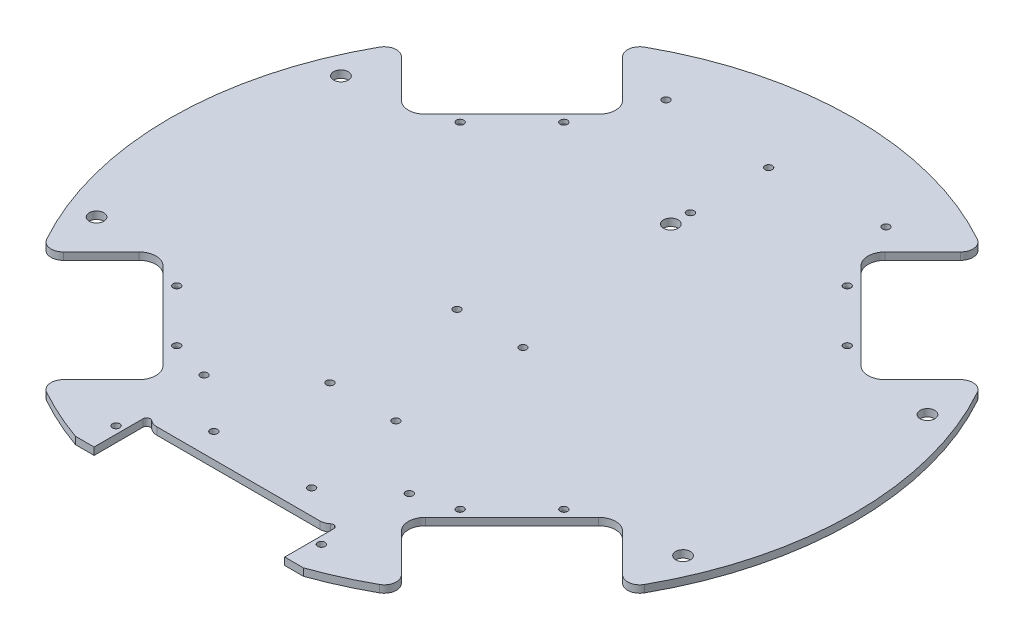
from build123d import *

# Parameters (mm, degrees)
SKETCH1_R                = 140
BOSS_EXTRUDE1_DEPTH      = 3
CUT_EXTRUDE4_DEPTH       = 3
SKETCH9_R                = 1.5
CUT_EXTRUDE6_DEPTH       = 3
FILLET1_R                = 5
CIRPATTERN1_COUNT        = 4
FILLET1_OF_CIRPATTERN1_R = 5
CUT_EXTRUDE1_REACH       = 5
FILLET3_R                = 1.5
CUT_EXTRUDE7_REACH       = 5
SKETCH10_R               = 1.5
CUT_EXTRUDE8_REACH       = 5
SKETCH11_R               = 1.5
CUT_EXTRUDE9_REACH       = 5
SKETCH13_R               = 1.5
CUT_EXTRUDE12_REACH      = 5
SKETCH16_R               = 1.5
SKETCH16_R_2             = 3
CUT_EXTRUDE13_REACH      = 5
SKETCH17_R               = 3


with BuildPart() as part:
    # Sketch1 → Boss-Extrude1 (new body)
    with BuildSketch(Plane(origin=(0, 0, 0), x_dir=(1, 0, 0), z_dir=(0, 1, 0))):
        Circle(SKETCH1_R)
    extrude(amount=BOSS_EXTRUDE1_DEPTH)

    # Sketch7 → Cut-Extrude4 (cut)
    with BuildSketch(Plane(origin=(0, 3, 0), x_dir=(1, 0, 0), z_dir=(0, 1, 0))):
        with BuildLine():
            Line((-89.130809769, -53.704760031), (-53.704760031, -89.130809769))
            ThreePointArc((-53.704760031, -89.130809769), (-51.66915216, -94.045201898), (-53.704760031, -98.959594027))
            Line((-53.704760031, -98.959594027), (-76.367532368, -121.622366364))
            Line((-76.367532368, -121.622366364), (-121.622366364, -76.367532368))
            Line((-121.622366364, -76.367532368), (-98.959594027, -53.704760031))
            ThreePointArc((-98.959594027, -53.704760031), (-94.045201898, -51.66915216), (-89.130809769, -53.704760031))
        make_face()
    cut_extrude4 = extrude(amount=-CUT_EXTRUDE4_DEPTH, mode=Mode.SUBTRACT)

    # Sketch9 → Cut-Extrude6 (cut)
    with BuildSketch(Plane(origin=(0, 3, 0), x_dir=(1, 0, 0), z_dir=(0, 1, 0))):
        with Locations((-79.195959493, -57.982756057)):
            Circle(SKETCH9_R)
        with Locations((-57.982756057, -79.195959493)):
            Circle(SKETCH9_R)
    cut_extrude6 = extrude(amount=-CUT_EXTRUDE6_DEPTH, mode=Mode.SUBTRACT)

    # Fillet1
    fillet1_edges = [part.edges().sort_by_distance(p)[0] for p in [
        (-119.001687423, 1.5, 73.746853427),
        (-73.746853427, 1.5, 119.001687423),
    ]]
    fillet(fillet1_edges, radius=FILLET1_R)

    # CirPattern1: Cut-Extrude4, Cut-Extrude6 ×4 about axis
    cirpattern1_axis = Axis((0, 0, 0), (0, 1, 0))
    for i in range(1, CIRPATTERN1_COUNT):
        add(cut_extrude4.rotate(cirpattern1_axis, i * 360 / CIRPATTERN1_COUNT), mode=Mode.SUBTRACT)
        add(cut_extrude6.rotate(cirpattern1_axis, i * 360 / CIRPATTERN1_COUNT), mode=Mode.SUBTRACT)

    # Fillet1 of CirPattern1
    fillet1_of_cirpattern1_edges = [part.edges().sort_by_distance(p)[0] for p in [
        (73.746853427, 1.5, 119.001687423),
        (119.001687423, 1.5, 73.746853427),
        (119.001687423, 1.5, -73.746853427),
        (73.746853427, 1.5, -119.001687423),
        (-73.746853427, 1.5, -119.001687423),
        (-119.001687423, 1.5, -73.746853427),
    ]]
    fillet(fillet1_of_cirpattern1_edges, radius=FILLET1_OF_CIRPATTERN1_R)

    # Sketch2 → Cut-Extrude1 (cut, up to next)
    with BuildSketch(Plane(origin=(0, 3, 0), x_dir=(1, 0, 0), z_dir=(0, 1, 0)), mode=Mode.PRIVATE) as cut_extrude1_sk1:
        with BuildLine():
            Line((-46.647615159, -132), (-39, -132))
            Line((-39, -132), (-39, -112))
            ThreePointArc((-39, -112), (-38.137304912, -110.642118396), (-36.5415434, -110.846153846))
            ThreePointArc((-36.5415434, -110.846153846), (-35.04510362, -111.702699716), (-33.346688069, -112))
            Line((-33.346688069, -112), (33.346688069, -112))
            ThreePointArc((33.346688069, -112), (35.04510362, -111.702699716), (36.5415434, -110.846153846))
            ThreePointArc((36.5415434, -110.846153846), (38.137304912, -110.642118396), (39, -112))
            Line((39, -112), (39, -132))
            Line((39, -132), (46.647615159, -132))
            Line((46.647615159, -132), (46.647615159, -140))
            Line((46.647615159, -140), (-46.647615159, -140))
            Line((-46.647615159, -140), (-46.647615159, -132))
        make_face()
    cut_extrude1_tool1 = extrude(cut_extrude1_sk1.sketch, amount=-CUT_EXTRUDE1_REACH, mode=Mode.PRIVATE) & part.part
    add(cut_extrude1_tool1.solids().sort_by_distance((0, 3, 126.474871))[0], mode=Mode.SUBTRACT)

    # Fillet3
    fillet3_edges = [part.edges().sort_by_distance(p)[0] for p in [
        (57.982756057, 0, 80.695959493),
        (79.195959493, 0, 59.482756057),
        (80.695959493, 0, -57.982756057),
        (59.482756057, 0, -79.195959493),
        (-57.982756057, 0, -80.695959493),
        (-79.195959493, 0, -59.482756057),
        (-80.695959493, 0, 57.982756057),
        (-59.482756057, 0, 79.195959493),
    ]]
    fillet(fillet3_edges, radius=FILLET3_R)

    # Sketch10 → Cut-Extrude7 (cut, up to next)
    with BuildSketch(Plane(origin=(0, 3, 0), x_dir=(1, 0, 0), z_dir=(0, 1, 0)), mode=Mode.PRIVATE) as cut_extrude7_sk1:
        with Locations((-13.5, -61)):
            Circle(SKETCH10_R)
    cut_extrude7_tool1 = extrude(cut_extrude7_sk1.sketch, amount=-CUT_EXTRUDE7_REACH, mode=Mode.PRIVATE) & part.part
    add(cut_extrude7_tool1.solids().sort_by_distance((-13.5, 3, 61))[0], mode=Mode.SUBTRACT)
    # Sketch10 → Cut-Extrude7 (cut, up to next)
    with BuildSketch(Plane(origin=(0, 3, 0), x_dir=(1, 0, 0), z_dir=(0, 1, 0)), mode=Mode.PRIVATE) as cut_extrude7_sk2:
        with Locations((13.5, -61)):
            Circle(SKETCH10_R)
    cut_extrude7_tool2 = extrude(cut_extrude7_sk2.sketch, amount=-CUT_EXTRUDE7_REACH, mode=Mode.PRIVATE) & part.part
    add(cut_extrude7_tool2.solids().sort_by_distance((13.5, 3, 61))[0], mode=Mode.SUBTRACT)
    # Sketch10 → Cut-Extrude7 (cut, up to next)
    with BuildSketch(Plane(origin=(0, 3, 0), x_dir=(1, 0, 0), z_dir=(0, 1, 0)), mode=Mode.PRIVATE) as cut_extrude7_sk3:
        with Locations((-13.5, -9)):
            Circle(SKETCH10_R)
    cut_extrude7_tool3 = extrude(cut_extrude7_sk3.sketch, amount=-CUT_EXTRUDE7_REACH, mode=Mode.PRIVATE) & part.part
    add(cut_extrude7_tool3.solids().sort_by_distance((-13.5, 3, 9))[0], mode=Mode.SUBTRACT)
    # Sketch10 → Cut-Extrude7 (cut, up to next)
    with BuildSketch(Plane(origin=(0, 3, 0), x_dir=(1, 0, 0), z_dir=(0, 1, 0)), mode=Mode.PRIVATE) as cut_extrude7_sk4:
        with Locations((13.5, -9)):
            Circle(SKETCH10_R)
    cut_extrude7_tool4 = extrude(cut_extrude7_sk4.sketch, amount=-CUT_EXTRUDE7_REACH, mode=Mode.PRIVATE) & part.part
    add(cut_extrude7_tool4.solids().sort_by_distance((13.5, 3, 9))[0], mode=Mode.SUBTRACT)

    # Sketch11 → Cut-Extrude8 (cut, up to next)
    with BuildSketch(Plane(origin=(0, 3, 0), x_dir=(1, 0, 0), z_dir=(0, 1, 0)), mode=Mode.PRIVATE) as cut_extrude8_sk1:
        with Locations((-20, -102)):
            Circle(SKETCH11_R)
    cut_extrude8_tool1 = extrude(cut_extrude8_sk1.sketch, amount=-CUT_EXTRUDE8_REACH, mode=Mode.PRIVATE) & part.part
    add(cut_extrude8_tool1.solids().sort_by_distance((-20, 3, 102))[0], mode=Mode.SUBTRACT)
    # Sketch11 → Cut-Extrude8 (cut, up to next)
    with BuildSketch(Plane(origin=(0, 3, 0), x_dir=(1, 0, 0), z_dir=(0, 1, 0)), mode=Mode.PRIVATE) as cut_extrude8_sk2:
        with Locations((20, -102)):
            Circle(SKETCH11_R)
    cut_extrude8_tool2 = extrude(cut_extrude8_sk2.sketch, amount=-CUT_EXTRUDE8_REACH, mode=Mode.PRIVATE) & part.part
    add(cut_extrude8_tool2.solids().sort_by_distance((20, 3, 102))[0], mode=Mode.SUBTRACT)

    # Sketch13 → Cut-Extrude9 (cut, up to next)
    with BuildSketch(Plane(origin=(0, 3, 0), x_dir=(1, 0, 0), z_dir=(0, 1, 0)), mode=Mode.PRIVATE) as cut_extrude9_sk1:
        with Locations((-42, -84)):
            Circle(SKETCH13_R)
    cut_extrude9_tool1 = extrude(cut_extrude9_sk1.sketch, amount=-CUT_EXTRUDE9_REACH, mode=Mode.PRIVATE) & part.part
    add(cut_extrude9_tool1.solids().sort_by_distance((-42, 3, 84))[0], mode=Mode.SUBTRACT)
    # Sketch13 → Cut-Extrude9 (cut, up to next)
    with BuildSketch(Plane(origin=(0, 3, 0), x_dir=(1, 0, 0), z_dir=(0, 1, 0)), mode=Mode.PRIVATE) as cut_extrude9_sk2:
        with Locations((-42, -120)):
            Circle(SKETCH13_R)
    cut_extrude9_tool2 = extrude(cut_extrude9_sk2.sketch, amount=-CUT_EXTRUDE9_REACH, mode=Mode.PRIVATE) & part.part
    add(cut_extrude9_tool2.solids().sort_by_distance((-42, 3, 120))[0], mode=Mode.SUBTRACT)
    # Sketch13 → Cut-Extrude9 (cut, up to next)
    with BuildSketch(Plane(origin=(0, 3, 0), x_dir=(1, 0, 0), z_dir=(0, 1, 0)), mode=Mode.PRIVATE) as cut_extrude9_sk3:
        with Locations((42, -120)):
            Circle(SKETCH13_R)
    cut_extrude9_tool3 = extrude(cut_extrude9_sk3.sketch, amount=-CUT_EXTRUDE9_REACH, mode=Mode.PRIVATE) & part.part
    add(cut_extrude9_tool3.solids().sort_by_distance((42, 3, 120))[0], mode=Mode.SUBTRACT)
    # Sketch13 → Cut-Extrude9 (cut, up to next)
    with BuildSketch(Plane(origin=(0, 3, 0), x_dir=(1, 0, 0), z_dir=(0, 1, 0)), mode=Mode.PRIVATE) as cut_extrude9_sk4:
        with Locations((42, -84)):
            Circle(SKETCH13_R)
    cut_extrude9_tool4 = extrude(cut_extrude9_sk4.sketch, amount=-CUT_EXTRUDE9_REACH, mode=Mode.PRIVATE) & part.part
    add(cut_extrude9_tool4.solids().sort_by_distance((42, 3, 84))[0], mode=Mode.SUBTRACT)

    # Sketch16 → Cut-Extrude12 (cut, up to next)
    with BuildSketch(Plane(origin=(0, 3, 0), x_dir=(1, 0, 0), z_dir=(0, 1, 0)), mode=Mode.PRIVATE) as cut_extrude12_sk1:
        with Locations((0, 73)):
            Circle(SKETCH16_R)
    cut_extrude12_tool1 = extrude(cut_extrude12_sk1.sketch, amount=-CUT_EXTRUDE12_REACH, mode=Mode.PRIVATE) & part.part
    add(cut_extrude12_tool1.solids().sort_by_distance((0, 3, -73))[0], mode=Mode.SUBTRACT)
    # Sketch16 → Cut-Extrude12 (cut, up to next)
    with BuildSketch(Plane(origin=(0, 3, 0), x_dir=(1, 0, 0), z_dir=(0, 1, 0)), mode=Mode.PRIVATE) as cut_extrude12_sk2:
        with Locations((-45, 108)):
            Circle(SKETCH16_R)
    cut_extrude12_tool2 = extrude(cut_extrude12_sk2.sketch, amount=-CUT_EXTRUDE12_REACH, mode=Mode.PRIVATE) & part.part
    add(cut_extrude12_tool2.solids().sort_by_distance((-45, 3, -108))[0], mode=Mode.SUBTRACT)
    # Sketch16 → Cut-Extrude12 (cut, up to next)
    with BuildSketch(Plane(origin=(0, 3, 0), x_dir=(1, 0, 0), z_dir=(0, 1, 0)), mode=Mode.PRIVATE) as cut_extrude12_sk3:
        with Locations((45, 108)):
            Circle(SKETCH16_R)
    cut_extrude12_tool3 = extrude(cut_extrude12_sk3.sketch, amount=-CUT_EXTRUDE12_REACH, mode=Mode.PRIVATE) & part.part
    add(cut_extrude12_tool3.solids().sort_by_distance((45, 3, -108))[0], mode=Mode.SUBTRACT)
    # Sketch16 → Cut-Extrude12 (cut, up to next)
    with BuildSketch(Plane(origin=(0, 3, 0), x_dir=(1, 0, 0), z_dir=(0, 1, 0)), mode=Mode.PRIVATE) as cut_extrude12_sk4:
        with Locations((0, 105)):
            Circle(SKETCH16_R)
    cut_extrude12_tool4 = extrude(cut_extrude12_sk4.sketch, amount=-CUT_EXTRUDE12_REACH, mode=Mode.PRIVATE) & part.part
    add(cut_extrude12_tool4.solids().sort_by_distance((0, 3, -105))[0], mode=Mode.SUBTRACT)
    # Sketch16 → Cut-Extrude12 (cut, up to next)
    with BuildSketch(Plane(origin=(0, 3, 0), x_dir=(1, 0, 0), z_dir=(0, 1, 0)), mode=Mode.PRIVATE) as cut_extrude12_sk5:
        with Locations((0, 65)):
            Circle(SKETCH16_R_2)
    cut_extrude12_tool5 = extrude(cut_extrude12_sk5.sketch, amount=-CUT_EXTRUDE12_REACH, mode=Mode.PRIVATE) & part.part
    add(cut_extrude12_tool5.solids().sort_by_distance((0, 3, -65))[0], mode=Mode.SUBTRACT)

    # Sketch17 → Cut-Extrude13 (cut, up to next)
    with BuildSketch(Plane(origin=(0, 3, 0), x_dir=(1, 0, 0), z_dir=(0, 1, 0)), mode=Mode.PRIVATE) as cut_extrude13_sk1:
        with Locations((-120, 50)):
            Circle(SKETCH17_R)
    cut_extrude13_tool1 = extrude(cut_extrude13_sk1.sketch, amount=-CUT_EXTRUDE13_REACH, mode=Mode.PRIVATE) & part.part
    add(cut_extrude13_tool1.solids().sort_by_distance((-120, 3, -50))[0], mode=Mode.SUBTRACT)
    # Sketch17 → Cut-Extrude13 (cut, up to next)
    with BuildSketch(Plane(origin=(0, 3, 0), x_dir=(1, 0, 0), z_dir=(0, 1, 0)), mode=Mode.PRIVATE) as cut_extrude13_sk2:
        with Locations((-120, -50)):
            Circle(SKETCH17_R)
    cut_extrude13_tool2 = extrude(cut_extrude13_sk2.sketch, amount=-CUT_EXTRUDE13_REACH, mode=Mode.PRIVATE) & part.part
    add(cut_extrude13_tool2.solids().sort_by_distance((-120, 3, 50))[0], mode=Mode.SUBTRACT)
    # Sketch17 → Cut-Extrude13 (cut, up to next)
    with BuildSketch(Plane(origin=(0, 3, 0), x_dir=(1, 0, 0), z_dir=(0, 1, 0)), mode=Mode.PRIVATE) as cut_extrude13_sk3:
        with Locations((120, 50)):
            Circle(SKETCH17_R)
    cut_extrude13_tool3 = extrude(cut_extrude13_sk3.sketch, amount=-CUT_EXTRUDE13_REACH, mode=Mode.PRIVATE) & part.part
    add(cut_extrude13_tool3.solids().sort_by_distance((120, 3, -50))[0], mode=Mode.SUBTRACT)
    # Sketch17 → Cut-Extrude13 (cut, up to next)
    with BuildSketch(Plane(origin=(0, 3, 0), x_dir=(1, 0, 0), z_dir=(0, 1, 0)), mode=Mode.PRIVATE) as cut_extrude13_sk4:
        with Locations((120, -50)):
            Circle(SKETCH17_R)
    cut_extrude13_tool4 = extrude(cut_extrude13_sk4.sketch, amount=-CUT_EXTRUDE13_REACH, mode=Mode.PRIVATE) & part.part
    add(cut_extrude13_tool4.solids().sort_by_distance((120, 3, 50))[0], mode=Mode.SUBTRACT)


solid = part.part
